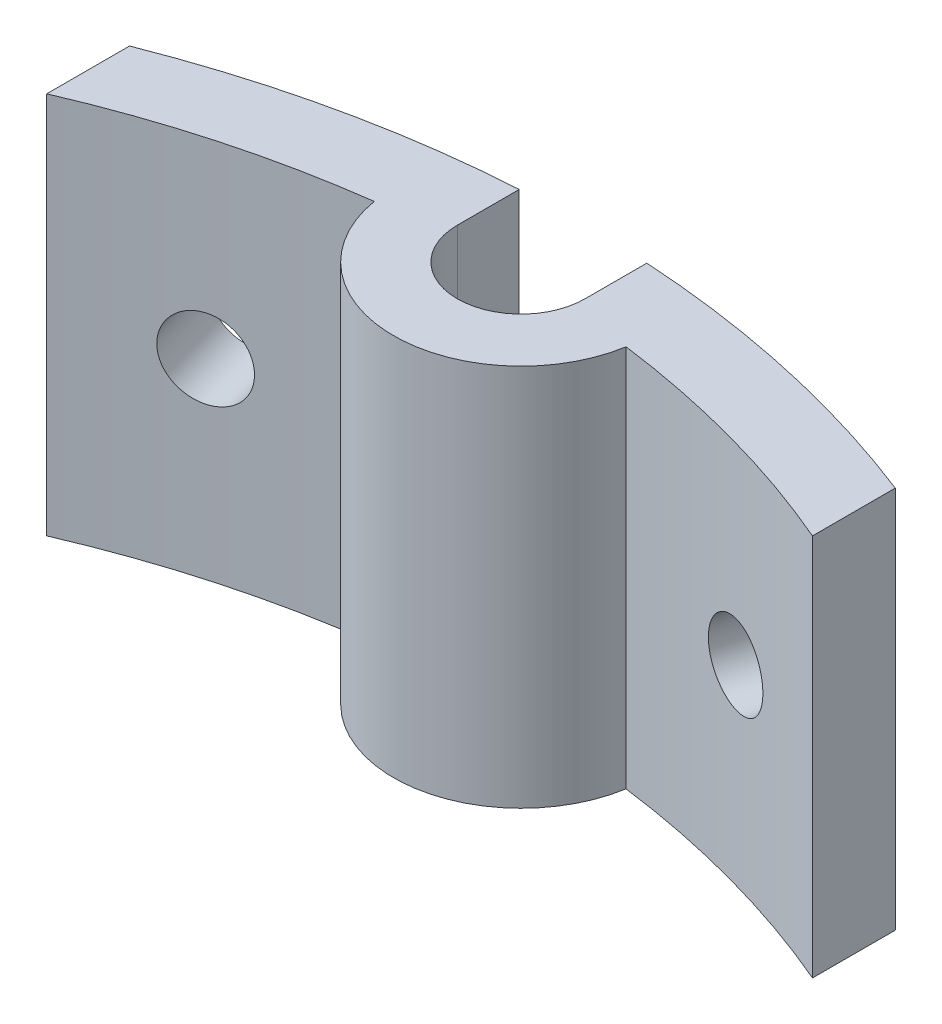
from build123d import *

# Parameters (mm, degrees)
BOSS_EXTRU_1_DEPTH             = 15
D_GAGEMENT_M41_D               = 3.1
D_GAGEMENT_M41_DEPTH           = 30
D_GAGEMENT_M41_TIP             = 0.931333959
D_GAGEMENT_M41_ON_FACE_2_D     = 3.1
D_GAGEMENT_M41_ON_FACE_2_DEPTH = 30
D_GAGEMENT_M41_ON_FACE_2_TIP   = 0.931333959


with BuildPart() as part:
    # Esquisse1 → Boss.-Extru.1 (new body)
    with BuildSketch(Plane(origin=(0, 0, 0), x_dir=(1, 0, 0), z_dir=(0, 1, 0))):
        with BuildLine():
            Line((-2.5, 38.5), (-2.5, 40.923709509))
            ThreePointArc((-2.5, 40.923709509), (-8.858633339, 40.031545253), (-15, 38.157568057))
            Line((-15, 38.157568057), (-15, 34.9141805))
            ThreePointArc((-15, 34.9141805), (-10.061424249, 36.64379541), (-4.93206398, 37.678571429))
            ThreePointArc((-4.93206398, 37.678571429), (-3.232093528, 34.685085659), (0, 33.5))
            ThreePointArc((0, 33.5), (3.232093528, 34.685085659), (4.93206398, 37.678571429))
            ThreePointArc((4.93206398, 37.678571429), (10.061424249, 36.64379541), (15, 34.9141805))
            Line((15, 34.9141805), (15, 38.157568057))
            ThreePointArc((15, 38.157568057), (8.858633339, 40.031545253), (2.5, 40.923709509))
            Line((2.5, 40.923709509), (2.5, 38.5))
            ThreePointArc((2.5, 38.5), (0, 36), (-2.5, 38.5))
        make_face()
    extrude(amount=BOSS_EXTRU_1_DEPTH)

    # Dégagement M41
    with Locations(Plane(origin=(-11.210356129, 7.5, -39.437645917), x_dir=(-0.961893803, 0, 0.27342332), z_dir=(-0.27342332, 0, -0.961893803))):
        with Locations((0, 0)):
            Hole(D_GAGEMENT_M41_D / 2, depth=D_GAGEMENT_M41_DEPTH)
            with Locations((0, 0, -(D_GAGEMENT_M41_DEPTH + D_GAGEMENT_M41_TIP / 2))):  # 118° drill point
                Cone(0, D_GAGEMENT_M41_D / 2, D_GAGEMENT_M41_TIP, mode=Mode.SUBTRACT)

    # Dégagement M41 on face 2
    with Locations(Plane(origin=(11.210356129, 7.5, -39.437645917), x_dir=(-0.961893902, 0, -0.273422972), z_dir=(0.273422972, 0, -0.961893902))):
        with Locations((0, 0)):
            Hole(D_GAGEMENT_M41_ON_FACE_2_D / 2, depth=D_GAGEMENT_M41_ON_FACE_2_DEPTH)
            with Locations((0, 0, -(D_GAGEMENT_M41_ON_FACE_2_DEPTH + D_GAGEMENT_M41_ON_FACE_2_TIP / 2))):  # 118° drill point
                Cone(0, D_GAGEMENT_M41_ON_FACE_2_D / 2, D_GAGEMENT_M41_ON_FACE_2_TIP, mode=Mode.SUBTRACT)


solid = part.part
